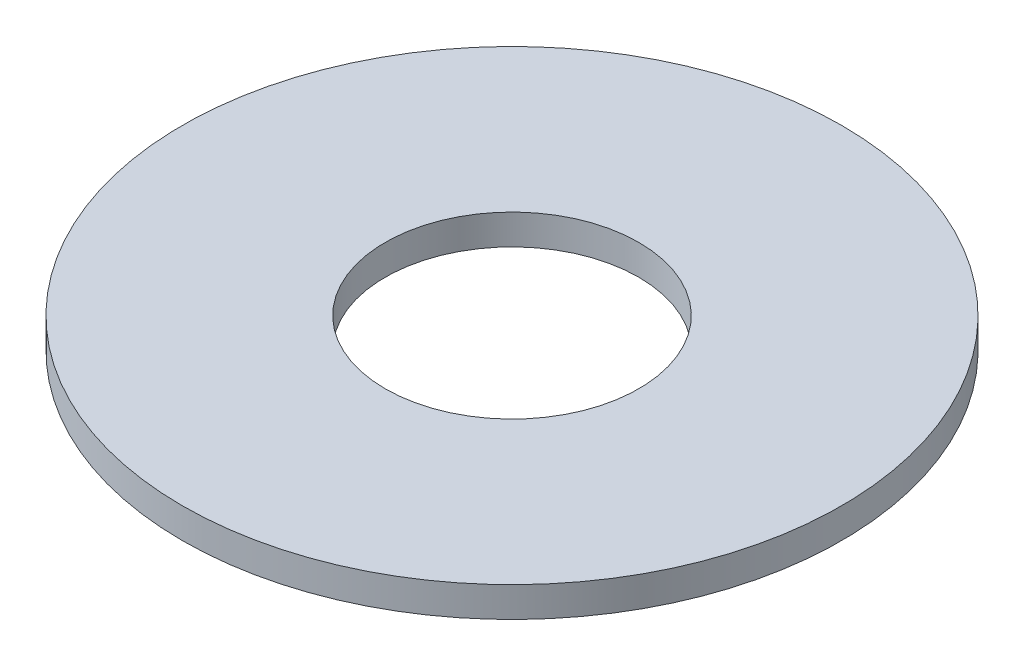
from build123d import *

# Parameters (mm, degrees)
SKETCH1_R           = 34.6583
SKETCH1_R_2         = 13.335
BOSS_EXTRUDE1_DEPTH = 3.175


with BuildPart() as part:
    # Sketch1 → Boss-Extrude1 (new body)
    with BuildSketch(Plane(origin=(0, 0, 0), x_dir=(1, 0, 0), z_dir=(0, 1, 0))):
        Circle(SKETCH1_R)
        Circle(SKETCH1_R_2, mode=Mode.SUBTRACT)
    extrude(amount=BOSS_EXTRUDE1_DEPTH)


solid = part.part
